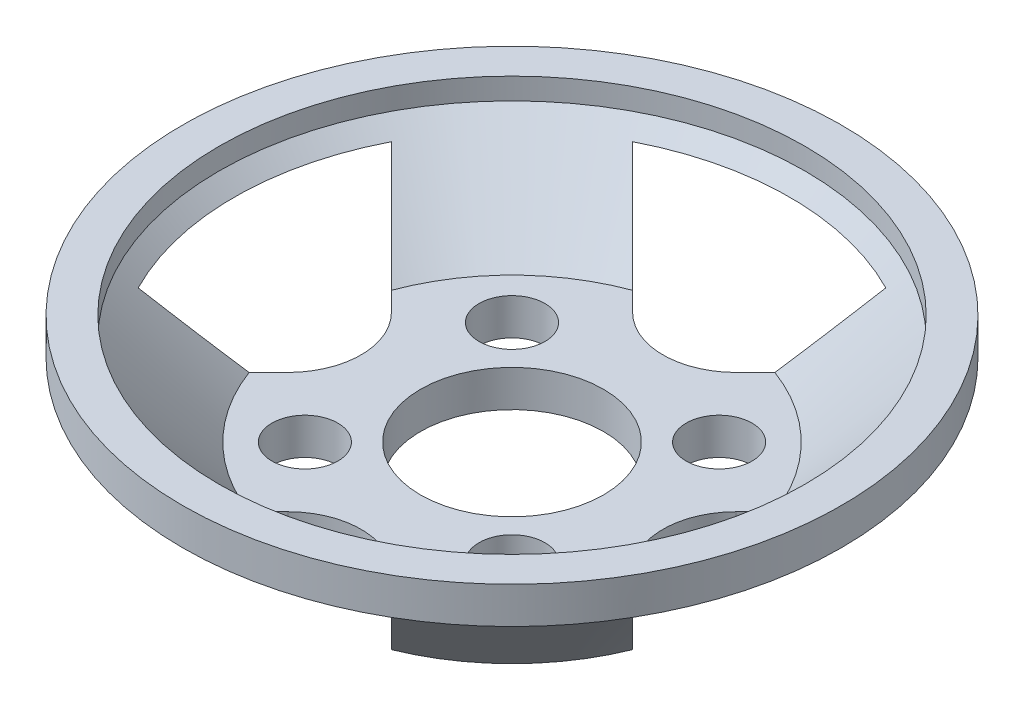
from build123d import *

# Parameters (mm, degrees)
IZIM1_R                     = 9
Y_KSEKLIK_EKSTR_ZYON1_DEPTH = 4
PAH1_SIZE                   = 3
BO_ALTMA1_T                 = -1
IZIM2_R                     = 2.5
KES_EKSTR_ZYON1_DEPTH       = 3
IZIM3_R                     = 0.9
KES_EKSTR_ZYON2_DEPTH       = 1


with BuildPart() as part:
    # Çizim1 → Yükseklik-Ekstrüzyon1 (new body)
    with BuildSketch(Plane(origin=(0, 0, 0), x_dir=(1, 0, 0), z_dir=(0, 1, 0))):
        with Locations(Location((0, 0, 0), (0, 0, 270))):
            Circle(IZIM1_R)
    extrude(amount=Y_KSEKLIK_EKSTR_ZYON1_DEPTH)

    # Pah1
    pah1_edges = [part.edges().sort_by_distance(p)[0] for p in [
        (0, 0, -9),
    ]]
    chamfer(pah1_edges, length=PAH1_SIZE)

    # İç Boşaltma1
    bo_altma1_openings = [part.faces().sort_by_distance(p)[0] for p in [
        (0, 4, 0),
    ]]
    offset(amount=BO_ALTMA1_T, openings=bo_altma1_openings, kind=Kind.INTERSECTION)

    # Çizim2 → Kes-Ekstrüzyon1 (cut)
    with BuildSketch(Plane.XZ):
        with Locations(Location((0, 0, 0), (0, 0, 270))):
            Circle(IZIM2_R)
        with BuildLine():
            Line((-4.5, 7.794228634), (-1.414213562, 4.708442196))
            ThreePointArc((-1.414213562, 4.708442196), (0, 4.122655759), (1.414213562, 4.708442196))
            Line((1.414213562, 4.708442196), (4.5, 7.794228634))
            ThreePointArc((4.5, 7.794228634), (0, 9), (-4.5, 7.794228634))
        make_face()
        with BuildLine():
            Line((7.794228634, 4.5), (4.708442196, 1.414213562))
            ThreePointArc((4.708442196, 1.414213562), (4.122655759, 0), (4.708442196, -1.414213562))
            Line((4.708442196, -1.414213562), (7.794228634, -4.5))
            ThreePointArc((7.794228634, -4.5), (9, 0), (7.794228634, 4.5))
        make_face()
        with BuildLine():
            Line((4.5, -7.794228634), (1.414213562, -4.708442196))
            ThreePointArc((1.414213562, -4.708442196), (0, -4.122655759), (-1.414213562, -4.708442196))
            Line((-1.414213562, -4.708442196), (-4.5, -7.794228634))
            ThreePointArc((-4.5, -7.794228634), (0, -9), (4.5, -7.794228634))
        make_face()
        with BuildLine():
            Line((-7.794228634, -4.5), (-4.708442196, -1.414213562))
            ThreePointArc((-4.708442196, -1.414213562), (-4.122655759, 0), (-4.708442196, 1.414213562))
            Line((-4.708442196, 1.414213562), (-7.794228634, 4.5))
            ThreePointArc((-7.794228634, 4.5), (-9, 0), (-7.794228634, -4.5))
        make_face()
    extrude(amount=-KES_EKSTR_ZYON1_DEPTH, mode=Mode.SUBTRACT)

    # Çizim3 → Kes-Ekstrüzyon2 (cut)
    with BuildSketch(Plane.XZ):
        with Locations(Location((-2.828427125, 2.828427125, 0), (0, 0, 270))):
            Circle(IZIM3_R)
        with Locations(Location((2.828427125, 2.828427125, 0), (0, 0, 270))):
            Circle(IZIM3_R)
        with Locations(Location((2.828427125, -2.828427125, 0), (0, 0, 270))):
            Circle(IZIM3_R)
        with Locations(Location((-2.828427125, -2.828427125, 0), (0, 0, 270))):
            Circle(IZIM3_R)
    extrude(amount=-KES_EKSTR_ZYON2_DEPTH, mode=Mode.SUBTRACT)


solid = part.part
